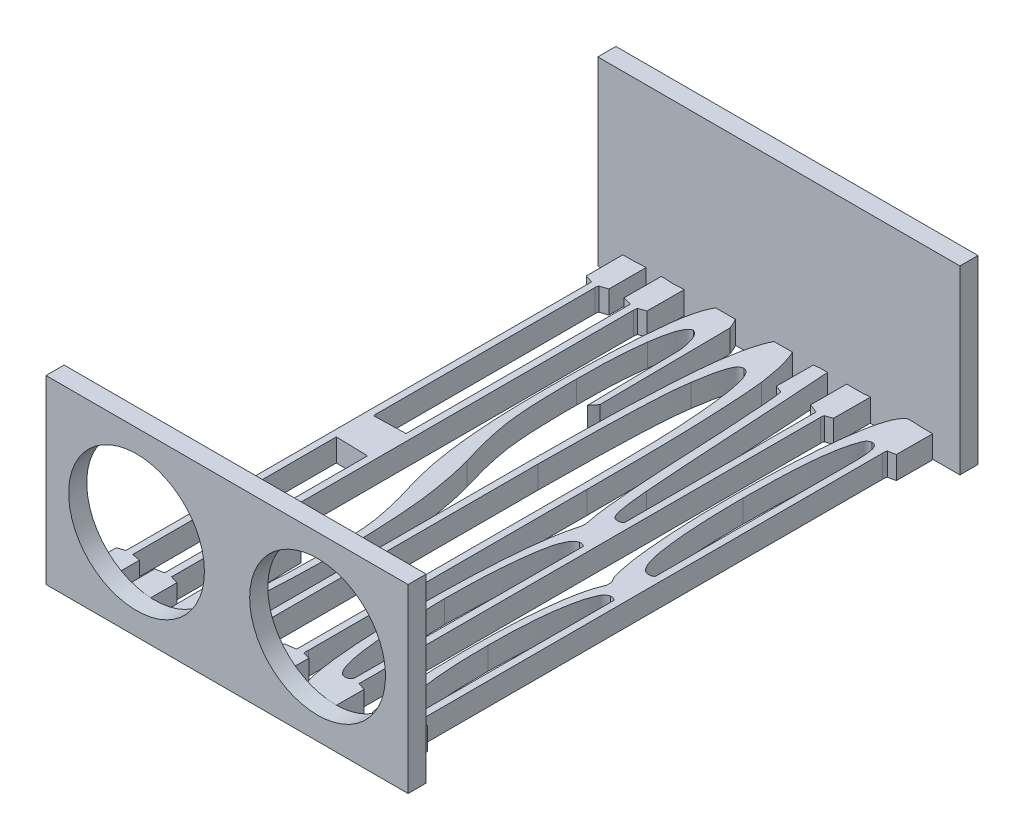
from build123d import *

# Parameters (mm, degrees)
SKETCH1_W           = 50.8
SKETCH1_H           = 2.54
BOSS_EXTRUDE1_DEPTH = 25.4
BOSS_EXTRUDE3_DEPTH = 3.175
SKETCH6_W           = 50.8
SKETCH6_H           = 25.4
BOSS_EXTRUDE8_DEPTH = 1.27
SKETCH7_W           = 50.8
SKETCH7_H           = 25.4
BOSS_EXTRUDE9_DEPTH = 1.27
SKETCH8_R           = 9.525
CUT_EXTRUDE1_DEPTH  = 2.54


with BuildPart() as part:
    # Sketch1 → Boss-Extrude1 (new body)
    with BuildSketch(Plane(origin=(0, 0, 0), x_dir=(1, 0, 0), z_dir=(0, 1, 0))):
        Rectangle(SKETCH1_W, SKETCH1_H)
    extrude(amount=BOSS_EXTRUDE1_DEPTH)

    # Sketch4 → Boss-Extrude3 (add)
    with BuildSketch(Plane.XZ):
        with BuildLine():
            add(Edge.make_bspline(
                [(21.648221196, 1.346192156), (21.35588042, 1.342760411), (20.808305646, 1.336332511), (20.260695616, 1.337514947), (20.005445185, 1.338066101)],
                knots=[0, 0, 0, 0, 0.00087707, 0.001642814, 0.001642814, 0.001642814, 0.001642814], degree=3))
            add(Edge.make_bspline(
                [(20.005445185, 1.338066101), (19.897668478, 1.332592274), (19.636528058, 1.31932932), (19.216023201, 1.292337392), (18.787141904, 1.231775147), (18.508136544, 1.222790798), (18.388875287, 1.218950424)],
                knots=[0, 0, 0, 0, 0.000323761, 0.000784466, 0.001263656, 0.001621408, 0.001621408, 0.001621408, 0.001621408], degree=3))
            add(Edge.make_bspline(
                [(18.388875287, 1.218950424), (18.258416324, 1.24787881), (17.975909749, 1.310522717), (17.630335273, 1.675745112), (17.29534666, 2.164678149), (16.995230901, 2.842688276), (16.731144627, 3.696101461), (16.45679766, 4.721550648), (16.230842353, 5.934801591), (16.003493781, 7.312124145), (15.830614418, 8.846816992), (15.651946397, 10.519009337), (15.524250565, 12.324349927), (15.405368626, 14.258623879), (15.299621236, 16.323114803), (15.233247623, 18.518682382), (15.203545921, 20.85026739), (15.19444692, 22.449896085), (15.189768543, 23.272367128)],
                knots=[0, 0, 0, 0, 0.000392857, 0.000850725, 0.00145018, 0.002181099, 0.003058234, 0.004131355, 0.005362792, 0.00675877, 0.008318546, 0.009994824, 0.011803706, 0.013747243, 0.015808773, 0.01800496, 0.020336472, 0.022803927, 0.022803927, 0.022803927, 0.022803927], degree=3))
            add(Edge.make_bspline(
                [(15.189768543, 23.272367128), (15.193636311, 24.441000315), (15.201092453, 26.693848384), (15.331756802, 29.932727816), (15.490201679, 32.907290705), (15.727859937, 35.567176869), (15.989502119, 37.856833901), (16.340209319, 39.665823942), (16.639024278, 41.027640519), (17.03767693, 41.678288589), (17.197718521, 41.93949531)],
                knots=[0, 0, 0, 0, 0.003505569, 0.006757908, 0.009723669, 0.012439764, 0.014772022, 0.016624323, 0.017987027, 0.018901022, 0.018901022, 0.018901022, 0.018901022], degree=3))
            Line((17.197718521, 41.93949531), (17.181715675, 42.631389885))
            add(Edge.make_bspline(
                [(17.181715675, 42.631389885), (17.019750482, 43.027451018), (16.659685676, 43.907934482), (16.27306747, 45.43185671), (15.943893452, 47.252515812), (15.655963, 49.358765511), (15.44298093, 51.732270408), (15.291962485, 54.354178993), (15.212257294, 57.21416812), (15.197461134, 59.199879506), (15.189768543, 60.232259937)],
                knots=[0, 0, 0, 0, 0.001282454, 0.002851023, 0.004703325, 0.006833111, 0.009225674, 0.01185069, 0.014710732, 0.017807926, 0.017807926, 0.017807926, 0.017807926], degree=3))
            add(Edge.make_bspline(
                [(15.189768543, 60.232259937), (15.202405449, 61.695841151), (15.226468505, 64.482776462), (15.388215818, 67.859705536), (15.607559132, 70.278384401), (15.75008507, 71.823856494), (15.931107135, 73.141511969), (16.088488465, 73.942461293), (16.159710482, 74.304926306)],
                knots=[0, 0, 0, 0, 0.004390791, 0.008360896, 0.010137229, 0.011676355, 0.013016778, 0.014124813, 0.014124813, 0.014124813, 0.014124813], degree=3))
            add(Edge.make_bspline(
                [(16.159710482, 74.304926306), (16.25206199, 74.58998506), (16.424320527, 75.12169055), (16.720266906, 75.833423174), (17.045960741, 76.401525428), (17.502371952, 76.930838238), (18.206142182, 77.384750155), (18.835404689, 77.407440166), (19.154618923, 77.418950424)],
                knots=[0, 0, 0, 0, 0.000898659, 0.001676223, 0.002309503, 0.002852168, 0.003768536, 0.004711994, 0.004711994, 0.004711994, 0.004711994], degree=3))
            add(Edge.make_bspline(
                [(19.154618923, 77.418950424), (19.575248197, 77.405394406), (20.402843383, 77.378722711), (21.220122197, 77.245989824), (21.622015082, 77.180719071)],
                knots=[0, 0, 0, 0, 0.001261061, 0.002481159, 0.002481159, 0.002481159, 0.002481159], degree=3))
            add(Edge.make_bspline(
                [(21.622015082, 77.180719071), (21.629051716, 76.386619433), (21.643677668, 74.736048463), (21.640618823, 73.085414333), (21.639031607, 72.228910228)],
                knots=[0, 0, 0, 0, 0.002382374, 0.00495187, 0.00495187, 0.00495187, 0.00495187], degree=3))
            Line((21.639031607, 72.228910228), (20.498941034, 72.015505719))
            Line((20.498941034, 72.015505719), (20.498941034, 7.233427974))
            add(Edge.make_bspline(
                [(20.498941034, 7.233427974), (20.489607917, 7.067054531), (20.477782497, 6.856252945), (20.565516409, 6.669553806), (20.584007043, 6.630205449)],
                knots=[0, 0, 0, 0, 0.0004853, 0.000614894, 0.000614894, 0.000614894, 0.000614894], degree=3))
            Line((20.584007043, 6.630205449), (21.633099088, 6.418844917))
            add(Edge.make_bspline(
                [(21.633099088, 6.418844917), (21.642664938, 5.570414703), (21.661759216, 3.876873357), (21.657949338, 2.183228758), (21.656048132, 1.338066101)],
                knots=[0, 0, 0, 0, 0.00254542, 0.005080882, 0.005080882, 0.005080882, 0.005080882], degree=3))
            Line((21.656048132, 1.338066101), (21.648221196, 1.346192156))
        make_face()
        with BuildLine():
            add(Edge.make_bspline(
                [(19.518978622, 71.785201009), (19.429585229, 71.86131712), (19.208208852, 72.049813252), (18.918778554, 72.098051678), (18.746222317, 72.126811076)],
                knots=[0, 0, 0, 0, 0.000346723, 0.000858635, 0.000858635, 0.000858635, 0.000858635], degree=3))
            add(Edge.make_bspline(
                [(18.746222317, 72.126811076), (18.521612363, 72.049827574), (17.992412544, 71.868448009), (17.482271672, 70.960170011), (17.062240223, 69.72616895), (16.730565267, 68.04585182), (16.477591419, 66.012288104), (16.266933065, 63.667571967), (16.179994357, 61.044117129), (16.166689263, 59.205642323), (16.159710482, 58.241326485)],
                knots=[0, 0, 0, 0, 0.000692888, 0.001632502, 0.002935128, 0.004657248, 0.00673417, 0.009091312, 0.011713845, 0.014606855, 0.014606855, 0.014606855, 0.014606855], degree=3))
            add(Edge.make_bspline(
                [(16.159710482, 58.241326485), (16.167539444, 57.180294691), (16.182327493, 55.176122472), (16.342425513, 52.344933624), (16.558882527, 49.858025103), (16.903318561, 47.758280073), (17.258622469, 46.044514596), (17.705961291, 44.83376375), (18.1134707, 43.922508891), (18.590787787, 43.733278142), (18.780255368, 43.658164359)],
                knots=[0, 0, 0, 0, 0.0031825, 0.006011391, 0.0085072, 0.01066132, 0.012407401, 0.013710027, 0.014611903, 0.015205533, 0.015205533, 0.015205533, 0.015205533], degree=3))
            add(Edge.make_bspline(
                [(18.780255368, 43.658164359), (18.950601827, 43.670059825), (19.22721301, 43.689375863), (19.457522019, 43.838938697), (19.545999003, 43.896395712)],
                knots=[0, 0, 0, 0, 0.00050076, 0.000813142, 0.000813142, 0.000813142, 0.000813142], degree=3))
            Line((19.545999003, 43.896395712), (19.518978622, 71.785201009))
        make_face(mode=Mode.SUBTRACT)
        with BuildLine():
            add(Edge.make_bspline(
                [(19.530162335, 38.138694869), (19.431031256, 38.213707629), (19.159799095, 38.418949752), (18.813075303, 38.38657029), (18.59307359, 38.366025011)],
                knots=[0, 0, 0, 0, 0.000363189, 0.000993719, 0.000993719, 0.000993719, 0.000993719], degree=3))
            add(Edge.make_bspline(
                [(18.59307359, 38.366025011), (18.481391132, 38.321477359), (18.238184958, 38.22446782), (17.925549705, 37.908589704), (17.665821379, 37.451887693), (17.404581761, 36.867035043), (17.199453458, 36.130788627), (16.987861711, 35.258902964), (16.830008274, 34.23884203), (16.510120145, 31.81332445), (16.216693854, 27.878839006), (16.179147167, 24.327841555), (16.159710482, 22.489606967)],
                knots=[0, 0, 0, 0, 0.000357752, 0.000779061, 0.001298553, 0.001930918, 0.002695337, 0.00358688, 0.004621954, 0.005789169, 0.010927399, 0.01644204, 0.01644204, 0.01644204, 0.01644204], degree=3))
            add(Edge.make_bspline(
                [(16.159710482, 22.489606967), (16.16468215, 21.803283617), (16.17425627, 20.481606178), (16.199380814, 18.56945672), (16.280122535, 16.811839353), (16.333871012, 15.199512956), (16.442650481, 13.747830534), (16.551489302, 12.441196185), (16.713895551, 11.291167619), (16.894715243, 10.026958272), (17.174164033, 8.758599055), (17.523644734, 7.637227499), (17.854527743, 6.819121011), (18.25952121, 6.680356857), (18.405891813, 6.630205449)],
                knots=[0, 0, 0, 0, 0.00205907, 0.003965225, 0.005736252, 0.007337253, 0.008804231, 0.010102961, 0.011270176, 0.012285764, 0.013941359, 0.01511993, 0.015913711, 0.01636296, 0.01636296, 0.01636296, 0.01636296], degree=3))
            add(Edge.make_bspline(
                [(18.405891813, 6.630205449), (18.51098921, 6.630912606), (18.712668326, 6.632269621), (18.978224126, 6.819546127), (19.182218076, 7.104998615), (19.337708909, 7.526052864), (19.422010038, 8.114108379), (19.514192843, 8.885059453), (19.53065176, 9.869136708), (19.540546478, 10.589484995), (19.545999003, 10.986435909)],
                knots=[0, 0, 0, 0, 0.000308182, 0.000591394, 0.000931724, 0.001352001, 0.001922753, 0.002710124, 0.003680663, 0.004871941, 0.004871941, 0.004871941, 0.004871941], degree=3))
            Line((19.545999003, 10.986435909), (19.530162335, 38.138694869))
        make_face(mode=Mode.SUBTRACT)
        with BuildLine():
            Line((11.774266104, 71.957410238), (11.786480114, 7.234258859))
            add(Edge.make_bspline(
                [(11.786480114, 7.234258859), (11.782269717, 7.121799091), (11.776013423, 6.954693368), (11.835180967, 6.799930719), (11.854529597, 6.749321126)],
                knots=[0, 0, 0, 0, 0.000332224, 0.000493657, 0.000493657, 0.000493657, 0.000493657], degree=3))
            Line((11.854529597, 6.749321126), (12.814783416, 6.418844917))
            add(Edge.make_bspline(
                [(12.814783416, 6.418844917), (12.817450807, 5.564731015), (12.822863938, 3.831415003), (12.835220404, 2.098134515), (12.841488061, 1.218950424)],
                knots=[0, 0, 0, 0, 0.002562351, 0.005199968, 0.005199968, 0.005199968, 0.005199968], degree=3))
            add(Edge.make_bspline(
                [(12.841488061, 1.218950424), (12.581117661, 1.26018158), (12.073725458, 1.340530065), (11.560071233, 1.33887289), (11.31000079, 1.338066101)],
                knots=[0, 0, 0, 0, 0.000789391, 0.001538311, 0.001538311, 0.001538311, 0.001538311], degree=3))
            add(Edge.make_bspline(
                [(11.31000079, 1.338066101), (11.020719861, 1.338066101), (10.447830178, 1.338066101), (9.874940495, 1.338066101), (9.591331741, 1.338066101)],
                knots=[0, 0, 0, 0, 0.000867843, 0.001718669, 0.001718669, 0.001718669, 0.001718669], degree=3))
            add(Edge.make_bspline(
                [(9.591331741, 1.338066101), (9.584212956, 2.200231954), (9.570256538, 3.890512877), (9.572980615, 5.580848669), (9.574315216, 6.408990621)],
                knots=[0, 0, 0, 0, 0.002586568, 0.00507098, 0.00507098, 0.00507098, 0.00507098], degree=3))
            Line((9.574315216, 6.408990621), (10.833538083, 6.877161095))
            Line((10.833538083, 6.877161095), (10.833538083, 33.778526014))
            add(Edge.make_bspline(
                [(10.833538083, 33.778526014), (10.762383924, 33.839584381), (10.52293527, 34.045058578), (10.19569406, 34.02434965), (9.965695296, 34.009794551)],
                knots=[0, 0, 0, 0, 0.000274902, 0.000925102, 0.000925102, 0.000925102, 0.000925102], degree=3))
            add(Edge.make_bspline(
                [(9.965695296, 34.009794551), (9.877012824, 33.994998736), (9.679192425, 33.961994311), (9.429029808, 33.700125902), (9.260382769, 33.283753672), (9.089804084, 32.712771759), (8.94118974, 31.949348481), (8.81259371, 30.971102821), (8.6774458, 29.768241362), (8.596924956, 28.887999931), (8.553323702, 28.411357749)],
                knots=[0, 0, 0, 0, 0.000264168, 0.000589268, 0.001023106, 0.001609868, 0.002374097, 0.003353546, 0.004569364, 0.00600522, 0.00600522, 0.00600522, 0.00600522], degree=3))
            add(Edge.make_bspline(
                [(8.553323702, 28.411357749), (8.484513605, 27.492522391), (8.335032641, 25.496472382), (8.110096031, 22.26384619), (7.902397685, 18.552688799), (7.645806943, 14.537887921), (7.427357792, 10.549183206), (7.206582295, 6.924589146), (6.999784483, 3.83378006), (6.874323713, 1.95066314), (6.817638128, 1.099834748)],
                knots=[0, 0, 0, 0, 0.00276423, 0.006004928, 0.009721121, 0.013914961, 0.018073822, 0.021705086, 0.024808818, 0.027366963, 0.027366963, 0.027366963, 0.027366963], degree=3))
            add(Edge.make_bspline(
                [(6.817638128, 1.099834748), (6.681759099, 1.12437432), (6.388616484, 1.177315487), (6.09193885, 1.204413192), (5.932778816, 1.218950424)],
                knots=[0, 0, 0, 0, 0.00041403, 0.00089322, 0.00089322, 0.00089322, 0.00089322], degree=3))
            add(Edge.make_bspline(
                [(5.932778816, 1.218950424), (5.757775668, 1.26030615), (5.427486231, 1.338358229), (5.088281609, 1.338159523), (4.928803827, 1.338066101)],
                knots=[0, 0, 0, 0, 0.000537302, 0.001014068, 0.001014068, 0.001014068, 0.001014068], degree=3))
            add(Edge.make_bspline(
                [(4.928803827, 1.338066101), (4.921718242, 2.200232063), (4.907500611, 3.930217353), (4.910355295, 5.6602588), (4.911787302, 6.528106297)],
                knots=[0, 0, 0, 0, 0.002586568, 0.005190096, 0.005190096, 0.005190096, 0.005190096], degree=3))
            Line((4.911787302, 6.528106297), (5.827057006, 6.877161095))
            add(Edge.make_bspline(
                [(5.827057006, 6.877161095), (5.852969092, 6.883742373), (5.97453468, 6.914618196), (5.946795518, 7.283291526), (6.093348045, 7.730907626), (6.113171212, 8.546012488), (6.252770997, 9.669921815), (6.321356534, 11.256048978), (6.501474986, 13.304136545), (6.584601891, 14.837282811), (6.63045635, 15.682996874)],
                knots=[0, 0, 0, 0, 7.6025e-05, 0.000356669, 0.000857429, 0.001609244, 0.00272002, 0.004288866, 0.006353554, 0.008893637, 0.008893637, 0.008893637, 0.008893637], degree=3))
            add(Edge.make_bspline(
                [(6.63045635, 15.682996874), (6.691136076, 17.050077092), (6.80621479, 19.642736075), (6.995644244, 23.318198959), (7.172672609, 26.569559244), (7.383516821, 29.393531322), (7.572603396, 31.789702522), (7.801505833, 33.756794334), (8.000203141, 35.299063946), (8.186139298, 36.177295584), (8.264042773, 36.545256811)],
                knots=[0, 0, 0, 0, 0.004105252, 0.007785585, 0.011041127, 0.013873241, 0.016281245, 0.018250609, 0.019814834, 0.020942812, 0.020942812, 0.020942812, 0.020942812], degree=3))
            Line((8.264042773, 36.545256811), (8.24765772, 37.124549848))
            add(Edge.make_bspline(
                [(8.24765772, 37.124549848), (8.117493499, 37.622246079), (7.829392476, 38.723829852), (7.480561122, 40.564158352), (7.180145719, 42.750841143), (6.932117047, 45.277182326), (6.733785211, 48.125874317), (6.578381906, 51.274416793), (6.500078151, 54.712838051), (6.485098763, 57.101187686), (6.477307623, 58.343425636)],
                knots=[0, 0, 0, 0, 0.001542984, 0.003415189, 0.005614735, 0.008163013, 0.011029073, 0.014180853, 0.017619244, 0.021346019, 0.021346019, 0.021346019, 0.021346019], degree=3))
            add(Edge.make_bspline(
                [(6.477307623, 58.343425636), (6.484668541, 59.330455088), (6.498970102, 61.248158943), (6.585481618, 64.03939015), (6.717162283, 66.661023784), (6.905972953, 69.07138828), (7.105347005, 71.214997752), (7.387780201, 73.004575168), (7.637956107, 74.440221474), (7.920870389, 75.237484673), (8.042827945, 75.581165699)],
                knots=[0, 0, 0, 0, 0.002961071, 0.005753078, 0.008377156, 0.010834675, 0.013007066, 0.01483125, 0.016272943, 0.017365319, 0.017365319, 0.017365319, 0.017365319], degree=3))
            add(Edge.make_bspline(
                [(8.042827945, 75.581165699), (8.197579068, 75.912631293), (8.454485585, 76.462906274), (8.956190126, 77.093218659), (9.527951074, 77.398246027), (9.916954564, 77.411876386), (10.118844023, 77.418950424)],
                knots=[0, 0, 0, 0, 0.001096081, 0.001819633, 0.002375217, 0.002974672, 0.002974672, 0.002974672, 0.002974672], degree=3))
            add(Edge.make_bspline(
                [(10.118844023, 77.418950424), (10.579125743, 77.405599161), (11.480096705, 77.379464947), (12.37146345, 77.246000257), (12.807455011, 77.180719071)],
                knots=[0, 0, 0, 0, 0.001380018, 0.002701294, 0.002701294, 0.002701294, 0.002701294], degree=3))
            add(Edge.make_bspline(
                [(12.807455011, 77.180719071), (12.814535399, 76.369602959), (12.828795027, 74.736046562), (12.825919345, 73.102430252), (12.824471536, 72.279959803)],
                knots=[0, 0, 0, 0, 0.002433423, 0.004900819, 0.004900819, 0.004900819, 0.004900819], degree=3))
            Line((12.824471536, 72.279959803), (11.774266104, 71.957410238))
        make_face()
        with BuildLine():
            add(Edge.make_bspline(
                [(10.788171761, 71.549213045), (10.717725959, 71.713102378), (10.560332132, 72.079272806), (10.155371793, 72.109894782), (9.931662246, 72.126811076)],
                knots=[0, 0, 0, 0, 0.000498239, 0.001113193, 0.001113193, 0.001113193, 0.001113193], degree=3))
            add(Edge.make_bspline(
                [(9.931662246, 72.126811076), (9.831911746, 72.112336983), (9.62591754, 72.082446614), (9.352718757, 71.856855235), (9.105404806, 71.529937151), (8.863229401, 71.070405759), (8.653569159, 70.485494801), (8.471661356, 69.770421421), (8.282116504, 68.937814184), (8.111603286, 67.973080703), (7.988603325, 66.874759757), (7.838326581, 65.651851188), (7.755961878, 64.298993618), (7.63550487, 62.820324487), (7.586929356, 61.213357662), (7.502475984, 59.472915183), (7.483382737, 57.605959963), (7.459538967, 56.318426863), (7.447249562, 55.654814649)],
                knots=[0, 0, 0, 0, 0.000297181, 0.000613707, 0.001025633, 0.001528125, 0.002163459, 0.00288581, 0.003740372, 0.004725127, 0.00582266, 0.00705539, 0.008420535, 0.009887514, 0.011505516, 0.013242536, 0.015114663, 0.017105887, 0.017105887, 0.017105887, 0.017105887], degree=3))
            add(Edge.make_bspline(
                [(7.447249562, 55.654814649), (7.464952442, 53.816412896), (7.499703203, 50.207629609), (7.821837674, 46.194435281), (8.164328782, 43.672060621), (8.35036764, 42.598915376), (8.547563089, 41.675731237), (8.777727523, 40.90258416), (9.056305382, 40.285013551), (9.327200431, 39.795217977), (9.661775497, 39.461608468), (9.916433083, 39.352296959), (10.033761397, 39.301933899)],
                knots=[0, 0, 0, 0, 0.005514641, 0.010825242, 0.012062192, 0.013150452, 0.01409176, 0.014893706, 0.015564079, 0.016121484, 0.016566849, 0.01694735, 0.01694735, 0.01694735, 0.01694735], degree=3))
            add(Edge.make_bspline(
                [(10.033761397, 39.301933899), (10.22020673, 39.284571552), (10.526689815, 39.25603093), (10.747180341, 39.460200002), (10.833538083, 39.540165252)],
                knots=[0, 0, 0, 0, 0.000528609, 0.000868939, 0.000868939, 0.000868939, 0.000868939], degree=3))
            Line((10.833538083, 39.540165252), (10.788171761, 71.549213045))
        make_face(mode=Mode.SUBTRACT)
        with BuildLine():
            Line((3.201510192, 72.134920514), (1.683582964, 72.35095062))
            add(Edge.make_bspline(
                [(1.683582964, 72.35095062), (1.674375906, 73.223482753), (1.656550335, 74.91277196), (1.659975125, 76.60215027), (1.661630982, 77.418950424)],
                knots=[0, 0, 0, 0, 0.002617712, 0.005068092, 0.005068092, 0.005068092, 0.005068092], degree=3))
            add(Edge.make_bspline(
                [(1.661630982, 77.418950424), (2.007633662, 77.418950424), (2.676950321, 77.418950424), (3.34626698, 77.418950424), (3.66958096, 77.418950424)],
                knots=[0, 0, 0, 0, 0.001038008, 0.00200795, 0.00200795, 0.00200795, 0.00200795], degree=3))
            add(Edge.make_bspline(
                [(3.66958096, 77.418950424), (3.907812313, 77.418950424), (4.401291545, 77.418950424), (4.894770776, 77.418950424), (5.150018655, 77.418950424)],
                knots=[0, 0, 0, 0, 0.000714694, 0.001480438, 0.001480438, 0.001480438, 0.001480438], degree=3))
            add(Edge.make_bspline(
                [(5.150018655, 77.418950424), (5.157080339, 76.590817621), (5.171493742, 74.900539383), (5.168541172, 73.210201674), (5.16703518, 72.348025904)],
                knots=[0, 0, 0, 0, 0.002484471, 0.005070983, 0.005070983, 0.005070983, 0.005070983], degree=3))
            Line((5.16703518, 72.348025904), (4.238687346, 72.134920514))
            add(Edge.make_bspline(
                [(4.238687346, 72.134920514), (4.216587226, 72.075906162), (4.13236437, 71.851004331), (4.159823141, 71.608214903), (4.180076717, 71.429133542)],
                knots=[0, 0, 0, 0, 0.000187662, 0.000715174, 0.000715174, 0.000715174, 0.000715174], degree=3))
            Line((4.180076717, 71.429133542), (4.163076809, 32.382655796))
            add(Edge.make_bspline(
                [(4.163076809, 32.382655796), (4.163824611, 31.087255227), (4.165276416, 28.572328128), (4.154990059, 24.911424118), (4.09754654, 21.474138329), (4.036497106, 18.25194809), (3.933720435, 15.222698554), (3.797060464, 12.369430006), (3.636637516, 9.673480997), (3.475564293, 7.934453531), (3.397316556, 7.08965163)],
                knots=[0, 0, 0, 0, 0.003886215, 0.007544808, 0.010982525, 0.014199369, 0.017213024, 0.020075039, 0.02276903, 0.025314124, 0.025314124, 0.025314124, 0.025314124], degree=3))
            add(Edge.make_bspline(
                [(3.397316556, 7.08965163), (3.310385672, 6.538833663), (3.148538734, 5.513326993), (2.867033231, 4.090390278), (2.542234067, 2.898329431), (2.218280918, 1.922223428), (1.847847918, 1.167333459), (1.443824256, 0.642210271), (1.000170819, 0.294987542), (0.673510709, 0.275221612), (0.521523791, 0.266025011)],
                knots=[0, 0, 0, 0, 0.001672907, 0.003114599, 0.004348855, 0.005376771, 0.006198689, 0.006852442, 0.007366893, 0.007814528, 0.007814528, 0.007814528, 0.007814528], degree=3))
            add(Edge.make_bspline(
                [(0.521523791, 0.266025011), (0.342932901, 0.313882041), (-0.049073114, 0.418927956), (-0.502332364, 0.947568459), (-0.912672058, 1.667416713), (-1.398965586, 3.014976788), (-1.899419408, 4.995857467), (-2.153432239, 6.672650471), (-2.286202872, 7.549097812)],
                knots=[0, 0, 0, 0, 0.000543731, 0.001193486, 0.002001905, 0.003041585, 0.005468454, 0.008126085, 0.008126085, 0.008126085, 0.008126085], degree=3))
            add(Edge.make_bspline(
                [(-2.286202872, 7.549097812), (-2.357236905, 8.155704458), (-2.513028083, 9.48610849), (-2.697398051, 11.664938287), (-2.837017398, 14.196557457), (-2.99617801, 17.088786434), (-3.138860251, 20.367096447), (-3.207888745, 24.066336699), (-3.284626827, 28.195533639), (-3.299430711, 31.094250767), (-3.307194387, 32.614439482)],
                knots=[0, 0, 0, 0, 0.001832183, 0.004018326, 0.00655841, 0.009438277, 0.012708285, 0.016401851, 0.020537427, 0.025097983, 0.025097983, 0.025097983, 0.025097983], degree=3))
            Line((-3.307194387, 32.614439482), (-3.339333019, 72.020623971))
            Line((-3.339333019, 72.020623971), (-4.292025784, 72.35095062))
            add(Edge.make_bspline(
                [(-4.292025784, 72.35095062), (-4.292917911, 73.223490602), (-4.294645166, 74.912823457), (-4.294313305, 76.602157148), (-4.29415285, 77.418950424)],
                knots=[0, 0, 0, 0, 0.002617621, 0.005068001, 0.005068001, 0.005068001, 0.005068001], degree=3))
            add(Edge.make_bspline(
                [(-4.29415285, 77.418950424), (-4.050249322, 77.418950424), (-3.539753565, 77.418950424), (-3.029257808, 77.418950424), (-2.762665579, 77.418950424)],
                knots=[0, 0, 0, 0, 0.000731711, 0.001531487, 0.001531487, 0.001531487, 0.001531487], degree=3))
            add(Edge.make_bspline(
                [(-2.762665579, 77.418950424), (-2.445023775, 77.418950424), (-1.809740166, 77.418950424), (-1.174456557, 77.418950424), (-0.856814753, 77.418950424)],
                knots=[0, 0, 0, 0, 0.000952925, 0.001905851, 0.001905851, 0.001905851, 0.001905851], degree=3))
            add(Edge.make_bspline(
                [(-0.856814753, 77.418950424), (-0.849724518, 76.573801096), (-0.835544208, 74.883521473), (-0.838380232, 73.193184749), (-0.839798228, 72.348025904)],
                knots=[0, 0, 0, 0, 0.002535519, 0.005070982, 0.005070982, 0.005070982, 0.005070982], degree=3))
            Line((-0.839798228, 72.348025904), (-2.300976008, 72.134920514))
            add(Edge.make_bspline(
                [(-2.300976008, 72.134920514), (-2.321603183, 72.087351924), (-2.385600146, 71.939767711), (-2.366924906, 71.777399448), (-2.354268973, 71.667364895)],
                knots=[0, 0, 0, 0, 0.000153772, 0.000477086, 0.000477086, 0.000477086, 0.000477086], degree=3))
            add(Edge.make_bspline(
                [(-2.354268973, 71.667364895), (-2.352444609, 70.101841393), (-2.348729768, 66.914062608), (-2.377635822, 62.05872121), (-2.369375088, 57.044494677), (-2.372275086, 51.945212056), (-2.3693107, 46.874290783), (-2.37779055, 41.967834154), (-2.34880347, 37.276987621), (-2.352474437, 34.225340459), (-2.354268973, 32.733555159)],
                knots=[0, 0, 0, 0, 0.004696561, 0.009563317, 0.014566175, 0.019739199, 0.024861173, 0.029778949, 0.034458524, 0.03893387, 0.03893387, 0.03893387, 0.03893387], degree=3))
            add(Edge.make_bspline(
                [(-2.354268973, 32.733555159), (-2.343651101, 31.440305182), (-2.323392677, 28.972842233), (-2.283271934, 25.461266424), (-2.183651953, 22.319488224), (-2.116873207, 19.54458892), (-1.985870988, 17.140398752), (-1.880050362, 15.102361935), (-1.734260146, 13.4387895), (-1.597400952, 12.455143397), (-1.537475762, 12.024443948)],
                knots=[0, 0, 0, 0, 0.003879917, 0.007402708, 0.010534904, 0.013309902, 0.015729183, 0.01775765, 0.019432287, 0.02073669, 0.02073669, 0.02073669, 0.02073669], degree=3))
            add(Edge.make_bspline(
                [(-1.537475762, 12.024443948), (-1.43662277, 11.359863015), (-1.246613526, 10.107778003), (-0.931385301, 8.62283703), (-0.581566296, 7.637770719), (-0.311300118, 7.09682691), (0.043493436, 6.720809599), (0.334181887, 6.647541459), (0.470474216, 6.613188924)],
                knots=[0, 0, 0, 0, 0.002017015, 0.0038001, 0.004543003, 0.005144628, 0.00561405, 0.006028429, 0.006028429, 0.006028429, 0.006028429], degree=3))
            add(Edge.make_bspline(
                [(0.470474216, 6.613188924), (0.614610713, 6.657893294), (0.935538594, 6.757430047), (1.28247071, 7.235627005), (1.60802174, 7.864863109), (1.918840043, 9.048891601), (2.258413715, 10.717835398), (2.426041266, 12.118936378), (2.512457244, 12.841237159)],
                knots=[0, 0, 0, 0, 0.00044243, 0.000985094, 0.001692867, 0.002581156, 0.004630217, 0.006810591, 0.006810591, 0.006810591, 0.006810591], degree=3))
            add(Edge.make_bspline(
                [(2.512457244, 12.841237159), (2.573107798, 13.362710075), (2.701466309, 14.466335377), (2.821897243, 16.233035749), (2.969369998, 18.199871649), (3.068762356, 20.424166195), (3.132208992, 22.99415703), (3.182037627, 26.000531677), (3.215122229, 29.494675976), (3.222968881, 31.984820227), (3.227151303, 33.312117017)],
                knots=[0, 0, 0, 0, 0.001574741, 0.003332722, 0.005311328, 0.007491835, 0.0100112, 0.013023557, 0.016512111, 0.020494014, 0.020494014, 0.020494014, 0.020494014], degree=3))
            Line((3.227151303, 33.312117017), (3.201510192, 72.134920514))
        make_face()
        with BuildLine():
            add(Edge.make_bspline(
                [(-6.014832641, 22.111737077), (-5.887639794, 21.966843114), (-5.613691247, 21.654769819), (-5.363884531, 21.323021058), (-5.230061738, 21.145301474)],
                knots=[0, 0, 0, 0, 0.000578197, 0.001245323, 0.001245323, 0.001245323, 0.001245323], degree=3))
            add(Edge.make_bspline(
                [(-5.230061738, 21.145301474), (-5.239939468, 19.60245645), (-5.259804198, 16.499699082), (-5.316259192, 11.84861661), (-5.364674821, 7.254128246), (-5.399962434, 4.219528264), (-5.417243516, 2.73342117)],
                knots=[0, 0, 0, 0, 0.00462862, 0.009308443, 0.013954235, 0.018412857, 0.018412857, 0.018412857, 0.018412857], degree=3))
            add(Edge.make_bspline(
                [(-5.417243516, 2.73342117), (-5.547216415, 2.387342888), (-5.784237063, 1.756229022), (-6.266663345, 0.976637893), (-6.829316339, 0.435405246), (-7.270140188, 0.308392196), (-7.476243069, 0.249008486)],
                knots=[0, 0, 0, 0, 0.001106074, 0.002017054, 0.002740607, 0.003375941, 0.003375941, 0.003375941, 0.003375941], degree=3))
            add(Edge.make_bspline(
                [(-7.476243069, 0.249008486), (-7.634179082, 0.264003671), (-7.966002688, 0.295508558), (-8.399457331, 0.632195157), (-8.797399434, 1.105771828), (-9.142984942, 1.766648869), (-9.469128466, 2.59828614), (-9.744628378, 3.615989892), (-10.002003818, 4.814197964), (-10.130349908, 5.676339852), (-10.198887107, 6.136726217)],
                knots=[0, 0, 0, 0, 0.000467258, 0.000981709, 0.001585256, 0.002324055, 0.00320251, 0.004263692, 0.00548189, 0.006877868, 0.006877868, 0.006877868, 0.006877868], degree=3))
            add(Edge.make_bspline(
                [(-10.198887107, 6.136726217), (-10.31443042, 7.270506249), (-10.561923742, 9.69905861), (-10.786399612, 13.593093018), (-10.917985481, 17.979285118), (-10.937382788, 21.065781818), (-10.947614217, 22.69380527)],
                knots=[0, 0, 0, 0, 0.003418628, 0.007322688, 0.011698053, 0.016582062, 0.016582062, 0.016582062, 0.016582062], degree=3))
            add(Edge.make_bspline(
                [(-10.947614217, 22.69380527), (-10.940972231, 23.953056729), (-10.928344025, 26.347233298), (-10.838291355, 29.735542888), (-10.644037739, 32.730651382), (-10.413202957, 35.376576084), (-10.098466817, 37.765284247), (-9.731467231, 39.981638452), (-9.275025921, 42.060282177), (-8.900476203, 43.387510459), (-8.718449411, 44.032527914)],
                knots=[0, 0, 0, 0, 0.003777822, 0.007182658, 0.010166427, 0.012780832, 0.015149004, 0.017392606, 0.019518855, 0.021529183, 0.021529183, 0.021529183, 0.021529183], degree=3))
            add(Edge.make_bspline(
                [(-8.718449411, 44.032527914), (-8.526572682, 44.649416277), (-8.156925973, 45.837839459), (-7.695672969, 47.58733895), (-7.322967918, 49.233517775), (-7.007101884, 50.858917828), (-6.801764563, 52.621516191), (-6.678881897, 54.671971536), (-6.589827895, 57.089103895), (-6.590840959, 58.825460435), (-6.591383757, 59.755797231)],
                knots=[0, 0, 0, 0, 0.001937942, 0.003733408, 0.005425932, 0.007001225, 0.008698191, 0.010744707, 0.013162551, 0.015953313, 0.015953313, 0.015953313, 0.015953313], degree=3))
            add(Edge.make_bspline(
                [(-6.591383757, 59.755797231), (-6.601558275, 60.782678313), (-6.620565758, 62.701041903), (-6.746957044, 65.37281669), (-6.893355283, 67.646392084), (-7.083586731, 69.019191953), (-7.169945615, 69.642398392)],
                knots=[0, 0, 0, 0, 0.003080414, 0.005754663, 0.008024249, 0.009911166, 0.009911166, 0.009911166, 0.009911166], degree=3))
            add(Edge.make_bspline(
                [(-7.169945615, 69.642398392), (-7.26302354, 70.183542669), (-7.423323007, 71.115505196), (-7.793269004, 72.210105633), (-8.088133396, 73.033428267), (-8.485849259, 73.166507884), (-8.633366785, 73.215868691)],
                knots=[0, 0, 0, 0, 0.001631902, 0.002810473, 0.003572425, 0.004021675, 0.004021675, 0.004021675, 0.004021675], degree=3))
            add(Edge.make_bspline(
                [(-8.633366785, 73.215868691), (-8.761801372, 73.176751415), (-9.07265112, 73.082076017), (-9.341770782, 72.525173801), (-9.621435754, 71.794446534), (-9.728692815, 71.184807427), (-9.790490501, 70.833555159)],
                knots=[0, 0, 0, 0, 0.000388782, 0.000940968, 0.00172169, 0.002783009, 0.002783009, 0.002783009, 0.002783009], degree=3))
            add(Edge.make_bspline(
                [(-9.790490501, 70.833555159), (-9.80880728, 70.657817406), (-9.858344119, 70.182543193), (-9.879350565, 69.70508189), (-9.892589652, 69.404167039)],
                knots=[0, 0, 0, 0, 0.000529977, 0.001433296, 0.001433296, 0.001433296, 0.001433296], degree=3))
            Line((-9.892589652, 69.404167039), (-10.132682188, 58.213857426))
            add(Edge.make_bspline(
                [(-10.132682188, 58.213857426), (-10.252858872, 58.346386819), (-10.495068679, 58.613492864), (-10.716788788, 58.897839933), (-10.82849854, 59.041103171)],
                knots=[0, 0, 0, 0, 0.000536507, 0.001081302, 0.001081302, 0.001081302, 0.001081302], degree=3))
            add(Edge.make_bspline(
                [(-10.82849854, 59.041103171), (-10.817225748, 60.49318084), (-10.79454807, 63.414351679), (-10.759388378, 67.776241144), (-10.732252474, 72.053190028), (-10.693982641, 74.860815926), (-10.675349813, 76.227793658)],
                knots=[0, 0, 0, 0, 0.004356363, 0.008763775, 0.013086106, 0.017187407, 0.017187407, 0.017187407, 0.017187407], degree=3))
            add(Edge.make_bspline(
                [(-10.675349813, 76.227793658), (-10.578878985, 76.550057573), (-10.405717169, 77.128510207), (-10.021675034, 77.854433205), (-9.532282591, 78.359977702), (-9.129047138, 78.460702021), (-8.939664239, 78.508008039)],
                knots=[0, 0, 0, 0, 0.00100628, 0.001806237, 0.002456438, 0.00303224, 0.00303224, 0.00303224, 0.00303224], degree=3))
            add(Edge.make_bspline(
                [(-8.939664239, 78.508008039), (-8.806274763, 78.482098233), (-8.526549077, 78.427763823), (-8.138060664, 78.167505207), (-7.798150693, 77.753772587), (-7.483366333, 77.203069856), (-7.172427319, 76.516401672), (-6.914185479, 75.678436551), (-6.654611974, 74.702821258), (-6.513533182, 73.999597664), (-6.43823503, 73.624265297)],
                knots=[0, 0, 0, 0, 0.000404478, 0.000848215, 0.00136687, 0.00200015, 0.002746553, 0.003623689, 0.004626654, 0.005774733, 0.005774733, 0.005774733, 0.005774733], degree=3))
            add(Edge.make_bspline(
                [(-6.43823503, 73.624265297), (-6.377652529, 73.15955376), (-6.249344676, 72.175339844), (-6.127031143, 70.589963244), (-5.985060419, 68.821088783), (-5.828621417, 66.13261959), (-5.655680774, 62.457763418), (-5.633203119, 59.432761017), (-5.621441818, 57.849946405)],
                knots=[0, 0, 0, 0, 0.001405693, 0.002977121, 0.004769034, 0.006729557, 0.011055805, 0.015803904, 0.015803904, 0.015803904, 0.015803904], degree=3))
            add(Edge.make_bspline(
                [(-5.621441818, 57.849946405), (-5.625028184, 56.635944878), (-5.631850969, 54.326400759), (-5.761216675, 51.047582447), (-5.919446188, 48.124320354), (-6.157682767, 45.530378097), (-6.462635322, 43.196587946), (-6.850521319, 41.067204491), (-7.23586415, 39.089467987), (-7.582089537, 37.842369281), (-7.748507473, 37.242934346)],
                knots=[0, 0, 0, 0, 0.003641695, 0.006928044, 0.009842841, 0.012423357, 0.014740918, 0.016900676, 0.018916398, 0.020782018, 0.020782018, 0.020782018, 0.020782018], degree=3))
            add(Edge.make_bspline(
                [(-7.748507473, 37.242934346), (-8.095142985, 36.067631208), (-8.764794136, 33.797110531), (-9.295254871, 31.188875233), (-9.58728347, 29.441802329), (-9.673722419, 28.434132803), (-9.782045941, 27.300830794), (-9.868777839, 26.035790408), (-9.914263319, 24.63961223), (-9.942062321, 23.113541923), (-9.987733811, 21.457490951), (-9.981113288, 20.311526932), (-9.977672278, 19.715913354)],
                knots=[0, 0, 0, 0, 0.003674466, 0.007098553, 0.007977008, 0.008986161, 0.010130831, 0.011392925, 0.012789214, 0.014321079, 0.015972033, 0.017758768, 0.017758768, 0.017758768, 0.017758768], degree=3))
            add(Edge.make_bspline(
                [(-9.977672278, 19.715913354), (-9.976754032, 18.831010187), (-9.974981798, 17.123128918), (-9.895402959, 14.648094226), (-9.724061169, 12.35577936), (-9.561927389, 10.889608515), (-9.484193047, 10.186659223)],
                knots=[0, 0, 0, 0, 0.002654632, 0.005123495, 0.00742702, 0.009548633, 0.009548633, 0.009548633, 0.009548633], degree=3))
            add(Edge.make_bspline(
                [(-9.484193047, 10.186659223), (-9.438706757, 9.834027702), (-9.353920293, 9.176722382), (-9.153319322, 8.267211466), (-8.975198472, 7.486148597), (-8.780821252, 6.830794061), (-8.538064536, 6.312750749), (-8.29651003, 5.922471959), (-8.02774565, 5.642874339), (-7.815009226, 5.573793839), (-7.714474422, 5.541147834)],
                knots=[0, 0, 0, 0, 0.001066082, 0.001987178, 0.002792007, 0.003470111, 0.004033458, 0.004500716, 0.004849866, 0.005162711, 0.005162711, 0.005162711, 0.005162711], degree=3))
            add(Edge.make_bspline(
                [(-7.714474422, 5.541147834), (-7.563591089, 5.615618805), (-7.215979958, 5.787188042), (-6.854062113, 6.394177859), (-6.541086616, 7.230778392), (-6.409952564, 7.902621251), (-6.336135878, 8.280808397)],
                knots=[0, 0, 0, 0, 0.000496113, 0.001142965, 0.002037263, 0.003188994, 0.003188994, 0.003188994, 0.003188994], degree=3))
            add(Edge.make_bspline(
                [(-6.336135878, 8.280808397), (-6.310417028, 8.456384932), (-6.246812749, 8.890596363), (-6.238805931, 9.329594673), (-6.234036727, 9.59108084)],
                knots=[0, 0, 0, 0, 0.000531886, 0.001315385, 0.001315385, 0.001315385, 0.001315385], degree=3))
            Line((-6.234036727, 9.59108084), (-6.014832641, 22.111737077))
        make_face()
        with BuildLine():
            add(Edge.make_bspline(
                [(-13.307477236, 6.472353913), (-13.295555304, 5.594747353), (-13.271767897, 3.843690273), (-13.276511835, 2.092478238), (-13.278878174, 1.218950424)],
                knots=[0, 0, 0, 0, 0.002633014, 0.005253559, 0.005253559, 0.005253559, 0.005253559], degree=3))
            add(Edge.make_bspline(
                [(-13.278878174, 1.218950424), (-13.551061431, 1.242710323), (-14.072461432, 1.288225288), (-14.594754762, 1.321947628), (-14.844398496, 1.338066101)],
                knots=[0, 0, 0, 0, 0.000819624, 0.00157009, 0.00157009, 0.00157009, 0.00157009], degree=3))
            add(Edge.make_bspline(
                [(-14.844398496, 1.338066101), (-15.122446482, 1.322591122), (-15.67330129, 1.291932866), (-16.222844287, 1.243123103), (-16.495001443, 1.218950424)],
                knots=[0, 0, 0, 0, 0.000835371, 0.001654995, 0.001654995, 0.001654995, 0.001654995], degree=3))
            add(Edge.make_bspline(
                [(-16.495001443, 1.218950424), (-16.502119301, 2.109477308), (-16.516082857, 3.856480826), (-16.51335521, 5.603537501), (-16.512017969, 6.460040197)],
                knots=[0, 0, 0, 0, 0.002671649, 0.005241144, 0.005241144, 0.005241144, 0.005241144], degree=3))
            Line((-16.512017969, 6.460040197), (-15.297430244, 6.818384288))
            Line((-15.297430244, 6.818384288), (-15.310724405, 38.255068625))
            Line((-15.310724405, 38.255068625), (-19.727509765, 38.374134449))
            add(Edge.make_bspline(
                [(-19.727509765, 38.374134449), (-19.740219985, 38.33760263), (-19.794158356, 38.182572524), (-19.78567507, 38.016500531), (-19.779190814, 37.889562305)],
                knots=[0, 0, 0, 0, 0.000115532, 0.000490282, 0.000490282, 0.000490282, 0.000490282], degree=3))
            Line((-19.779190814, 37.889562305), (-19.796190721, 7.296508765))
            add(Edge.make_bspline(
                [(-19.796190721, 7.296508765), (-19.792626581, 7.186170757), (-19.78730689, 7.021484693), (-19.73002749, 6.868029111), (-19.711124713, 6.817387226)],
                knots=[0, 0, 0, 0, 0.000327743, 0.000489176, 0.000489176, 0.000489176, 0.000489176], degree=3))
            Line((-19.711124713, 6.817387226), (-18.654272201, 6.472353913))
            add(Edge.make_bspline(
                [(-18.654272201, 6.472353913), (-18.647940649, 5.594738038), (-18.635307263, 3.843625378), (-18.637826812, 2.092469011), (-18.639083623, 1.218950424)],
                knots=[0, 0, 0, 0, 0.002632902, 0.005253447, 0.005253447, 0.005253447, 0.005253447], degree=3))
            add(Edge.make_bspline(
                [(-18.639083623, 1.218950424), (-18.905575576, 1.242973386), (-19.432502055, 1.290473261), (-19.960604647, 1.32232387), (-20.22162047, 1.338066101)],
                knots=[0, 0, 0, 0, 0.000802668, 0.001587091, 0.001587091, 0.001587091, 0.001587091], degree=3))
            add(Edge.make_bspline(
                [(-20.22162047, 1.338066101), (-20.482540523, 1.338066101), (-21.015724981, 1.338066101), (-21.548909438, 1.338066101), (-21.821173842, 1.338066101)],
                knots=[0, 0, 0, 0, 0.00078276, 0.001599553, 0.001599553, 0.001599553, 0.001599553], degree=3))
            add(Edge.make_bspline(
                [(-21.821173842, 1.338066101), (-21.821173842, 2.205908888), (-21.821173842, 3.913233586), (-21.821173842, 5.620558285), (-21.821173842, 6.460040197)],
                knots=[0, 0, 0, 0, 0.002603528, 0.005121974, 0.005121974, 0.005121974, 0.005121974], degree=3))
            Line((-21.821173842, 6.460040197), (-20.725651941, 6.818384288))
            Line((-20.725651941, 6.818384288), (-20.749132752, 71.656762802))
            add(Edge.make_bspline(
                [(-20.749132752, 71.656762802), (-20.752782148, 71.762562533), (-20.758203497, 71.919732971), (-20.777016746, 72.075800765), (-20.783165802, 72.126811076)],
                knots=[0, 0, 0, 0, 0.000317356, 0.000471447, 0.000471447, 0.000471447, 0.000471447], degree=3))
            Line((-20.783165802, 72.126811076), (-21.762313947, 72.458965672))
            add(Edge.make_bspline(
                [(-21.762313947, 72.458965672), (-21.765580486, 73.301171862), (-21.771992979, 74.954494225), (-21.770739312, 76.607828438), (-21.770124266, 77.418950424)],
                knots=[0, 0, 0, 0, 0.002526634, 0.004959997, 0.004959997, 0.004959997, 0.004959997], degree=3))
            add(Edge.make_bspline(
                [(-21.770124266, 77.418950424), (-21.514876387, 77.418950424), (-21.015724981, 77.418950424), (-20.516573574, 77.418950424), (-20.272670045, 77.418950424)],
                knots=[0, 0, 0, 0, 0.000765744, 0.001497454, 0.001497454, 0.001497454, 0.001497454], degree=3))
            add(Edge.make_bspline(
                [(-20.272670045, 77.418950424), (-20.000405642, 77.418950424), (-19.455876834, 77.418950424), (-18.911348027, 77.418950424), (-18.639083623, 77.418950424)],
                knots=[0, 0, 0, 0, 0.000816793, 0.001633586, 0.001633586, 0.001633586, 0.001633586], degree=3))
            add(Edge.make_bspline(
                [(-18.639083623, 77.418950424), (-18.631993388, 76.573801096), (-18.617813078, 74.883521473), (-18.620649102, 73.193184749), (-18.622067098, 72.348025904)],
                knots=[0, 0, 0, 0, 0.002535519, 0.005070982, 0.005070982, 0.005070982, 0.005070982], degree=3))
            Line((-18.622067098, 72.348025904), (-19.796190721, 72.134920514))
            Line((-19.796190721, 72.134920514), (-19.796190721, 43.561017282))
            Line((-19.796190721, 43.561017282), (-15.379521685, 43.667038211))
            add(Edge.make_bspline(
                [(-15.379521685, 43.667038211), (-15.357680493, 43.691582089), (-15.273885155, 43.785746484), (-15.291109698, 43.917844569), (-15.303844677, 44.015511389)],
                knots=[0, 0, 0, 0, 9.6171e-05, 0.000368966, 0.000368966, 0.000368966, 0.000368966], degree=3))
            Line((-15.303844677, 44.015511389), (-15.324483861, 71.656762802))
            add(Edge.make_bspline(
                [(-15.324483861, 71.656762802), (-15.326521856, 71.762581859), (-15.329549934, 71.919809131), (-15.34864936, 72.07580537), (-15.354894253, 72.126811076)],
                knots=[0, 0, 0, 0, 0.000317182, 0.000471274, 0.000471274, 0.000471274, 0.000471274], degree=3))
            Line((-15.354894253, 72.126811076), (-16.494037617, 72.35095062))
            add(Edge.make_bspline(
                [(-16.494037617, 72.35095062), (-16.494440783, 73.212146311), (-16.495231639, 74.901479492), (-16.495077168, 76.590812849), (-16.495001443, 77.418950424)],
                knots=[0, 0, 0, 0, 0.002583587, 0.005068, 0.005068, 0.005068, 0.005068], degree=3))
            add(Edge.make_bspline(
                [(-16.495001443, 77.418950424), (-16.22273704, 77.418950424), (-15.678208232, 77.418950424), (-15.133679425, 77.418950424), (-14.861415021, 77.418950424)],
                knots=[0, 0, 0, 0, 0.000816793, 0.001633586, 0.001633586, 0.001633586, 0.001633586], degree=3))
            add(Edge.make_bspline(
                [(-14.861415021, 77.418950424), (-14.606167142, 77.418950424), (-14.07865486, 77.418950424), (-13.551142578, 77.418950424), (-13.278878174, 77.418950424)],
                knots=[0, 0, 0, 0, 0.000765744, 0.001582537, 0.001582537, 0.001582537, 0.001582537], degree=3))
            add(Edge.make_bspline(
                [(-13.278878174, 77.418950424), (-13.271787938, 76.590817719), (-13.257607634, 74.934571733), (-13.260443655, 73.278267473), (-13.261861649, 72.450125056)],
                knots=[0, 0, 0, 0, 0.002484471, 0.004968884, 0.004968884, 0.004968884, 0.004968884], degree=3))
            Line((-13.261861649, 72.450125056), (-14.350902646, 72.134920514))
            Line((-14.350902646, 72.134920514), (-14.350902646, 7.296508765))
            add(Edge.make_bspline(
                [(-14.350902646, 7.296508765), (-14.343743343, 7.187170999), (-14.333157011, 7.025495214), (-14.295155191, 6.868280952), (-14.282853163, 6.817387226)],
                knots=[0, 0, 0, 0, 0.000327743, 0.000484627, 0.000484627, 0.000484627, 0.000484627], degree=3))
            Line((-14.282853163, 6.817387226), (-13.307477236, 6.472353913))
        make_face()
    extrude(amount=-BOSS_EXTRUDE3_DEPTH)

    # Sketch6 → Boss-Extrude8 (add)
    with BuildSketch(Plane.XY.offset(77.418950424)):
        with Locations((0, 12.7)):
            Rectangle(SKETCH6_W, SKETCH6_H)
    extrude(amount=-BOSS_EXTRUDE8_DEPTH)

    # Sketch7 → Boss-Extrude9 (add)
    with BuildSketch(Plane.XY.offset(77.418950424)):
        with Locations((0, 12.7)):
            Rectangle(SKETCH7_W, SKETCH7_H)
    extrude(amount=BOSS_EXTRUDE9_DEPTH)

    # Sketch8 → Cut-Extrude1 (cut)
    with BuildSketch(Plane.XY.offset(78.688950424)):
        with Locations((-12.7, 12.7)):
            Circle(SKETCH8_R)
    cut_extrude1 = extrude(amount=-CUT_EXTRUDE1_DEPTH, mode=Mode.SUBTRACT)

    # Mirror1: Cut-Extrude1 across plane
    add(cut_extrude1.mirror(Plane(origin=(0, 0, 0), x_dir=(0, 0, 1), z_dir=(1, 0, 0))), mode=Mode.SUBTRACT)


solid = part.part
